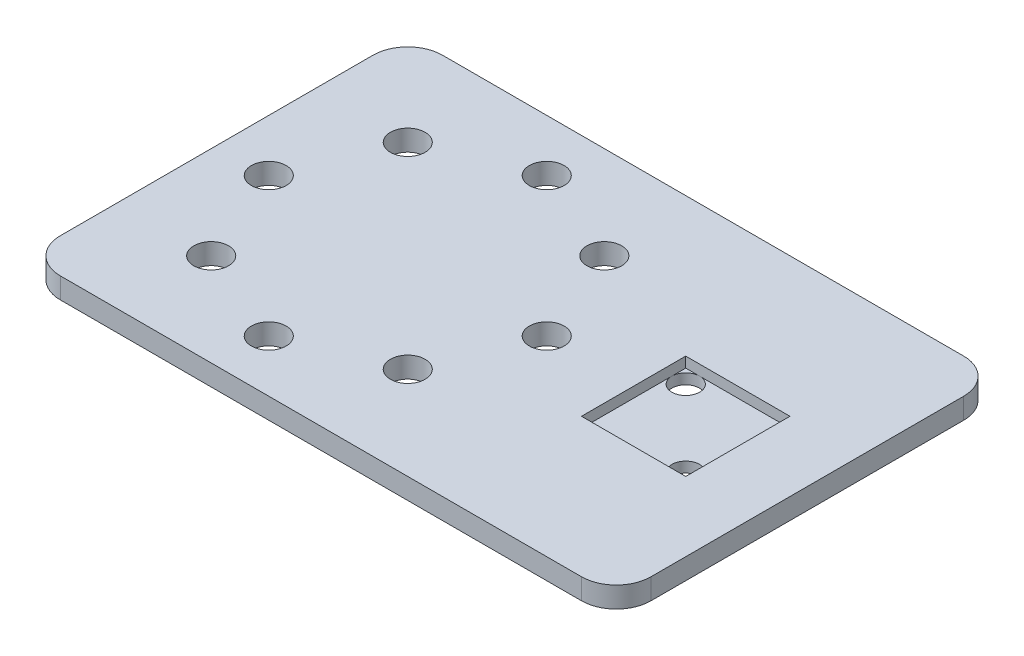
from build123d import *

# Parameters (mm, degrees)
SKETCH1_W           = 85
SKETCH1_H           = 55
SKETCH1_R           = 2.5
SKETCH1_W_2         = 15
SKETCH1_H_2         = 15
BOSS_EXTRUDE3_DEPTH = 3
FILLET2_R           = 5
BOSS_EXTRUDE4_REACH = 27
SKETCH2_W           = 15
SKETCH2_H           = 1.5
SKETCH3_R           = 2
CUT_EXTRUDE1_DEPTH  = 10


with BuildPart() as part:
    # Sketch1 → Boss-Extrude3 (new body)
    with BuildSketch(Plane(origin=(0, 0, 0), x_dir=(1, 0, 0), z_dir=(0, 1, 0))):
        with Locations((0, -0.433266932)):
            Rectangle(SKETCH1_W, SKETCH1_H)
        with Locations((-35, -0.433266932)):
            Circle(SKETCH1_R, mode=Mode.SUBTRACT)
        with Locations((-29.142135624, 13.708868691)):
            Circle(SKETCH1_R, mode=Mode.SUBTRACT)
        with Locations((-15, 19.566733068)):
            Circle(SKETCH1_R, mode=Mode.SUBTRACT)
        with Locations((-0.857864376, 13.708868691)):
            Circle(SKETCH1_R, mode=Mode.SUBTRACT)
        with Locations((5, -0.433266932)):
            Circle(SKETCH1_R, mode=Mode.SUBTRACT)
        with Locations((-0.857864376, -14.575402556)):
            Circle(SKETCH1_R, mode=Mode.SUBTRACT)
        with Locations((-15, -20.433266932)):
            Circle(SKETCH1_R, mode=Mode.SUBTRACT)
        with Locations((-29.142135624, -14.575402556)):
            Circle(SKETCH1_R, mode=Mode.SUBTRACT)
        with Locations((25, -0.433266932)):
            Rectangle(SKETCH1_W_2, SKETCH1_H_2, mode=Mode.SUBTRACT)
    extrude(amount=BOSS_EXTRUDE3_DEPTH)

    # Fillet2
    fillet2_edges = [part.edges().sort_by_distance(p)[0] for p in [
        (42.5, 1.5, 27.933266932),
        (-42.5, 1.5, 27.933266932),
        (-42.5, 1.5, -27.066733068),
        (42.5, 1.5, -27.066733068),
    ]]
    fillet(fillet2_edges, radius=FILLET2_R)

    # Sketch2 → Boss-Extrude4 (add, up to next)
    with BuildSketch(Plane(origin=(17.5, 0, 0), x_dir=(0, 0, -1), z_dir=(1, 0, 0)), mode=Mode.PRIVATE) as boss_extrude4_sk1:
        with Locations((-0.433266932, 0.75)):
            Rectangle(SKETCH2_W, SKETCH2_H)
    boss_extrude4_tool1 = extrude(boss_extrude4_sk1.sketch, amount=BOSS_EXTRUDE4_REACH, mode=Mode.PRIVATE) - part.part
    add(boss_extrude4_tool1.solids().sort_by_distance((17.5, 0.75, 0.433267))[0])

    # Sketch3 → Cut-Extrude1 (cut)
    with BuildSketch(Plane(origin=(0, 1.5, 0), x_dir=(1, 0, 0), z_dir=(0, 1, 0))):
        with Locations((30.5, -5.933266932)):
            Circle(SKETCH3_R)
        with Locations((19.5, 5.066733068)):
            Circle(SKETCH3_R)
    extrude(amount=-CUT_EXTRUDE1_DEPTH, mode=Mode.SUBTRACT)


solid = part.part
